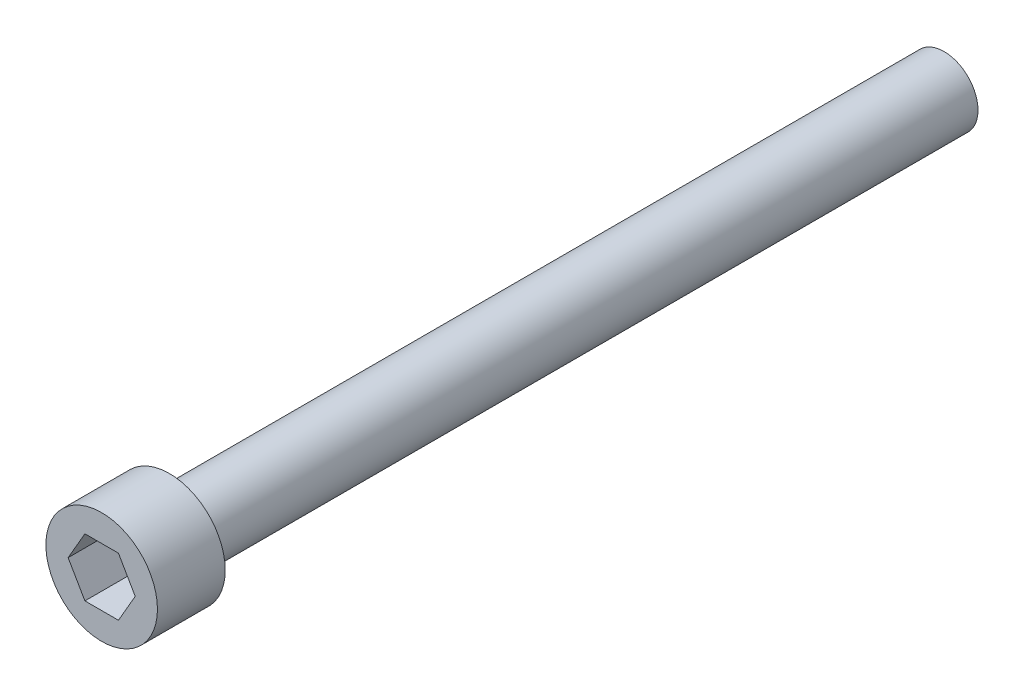
from build123d import *

# Parameters (mm, degrees)
F_9_64_ALLEN_DEPTH = 3.175


with BuildPart() as part:
    # Sketch1 → Revolve1 (revolve)
    with BuildSketch(Plane(origin=(0, 0, 0), x_dir=(1, 0, 0), z_dir=(0, 1, 0))):
        Polygon((0, 0), (0, 51.7906), (2.0828, 51.7906), (2.0828, 4.1656), (3.429, 4.1656), (3.429, 0), align=None)
    revolve(axis=Axis((0, 0, 0), (0, 0, -1)))

    # Sketch2 → 9-64 allen (cut)
    with BuildSketch(Plane.XY):
        Polygon((2.062222993, 0), (1.031111496, 1.7859375), (-1.031111496, 1.7859375), (-2.062222993, 0), (-1.031111496, -1.7859375), (1.031111496, -1.7859375), align=None)
    extrude(amount=-F_9_64_ALLEN_DEPTH, mode=Mode.SUBTRACT)


solid = part.part
